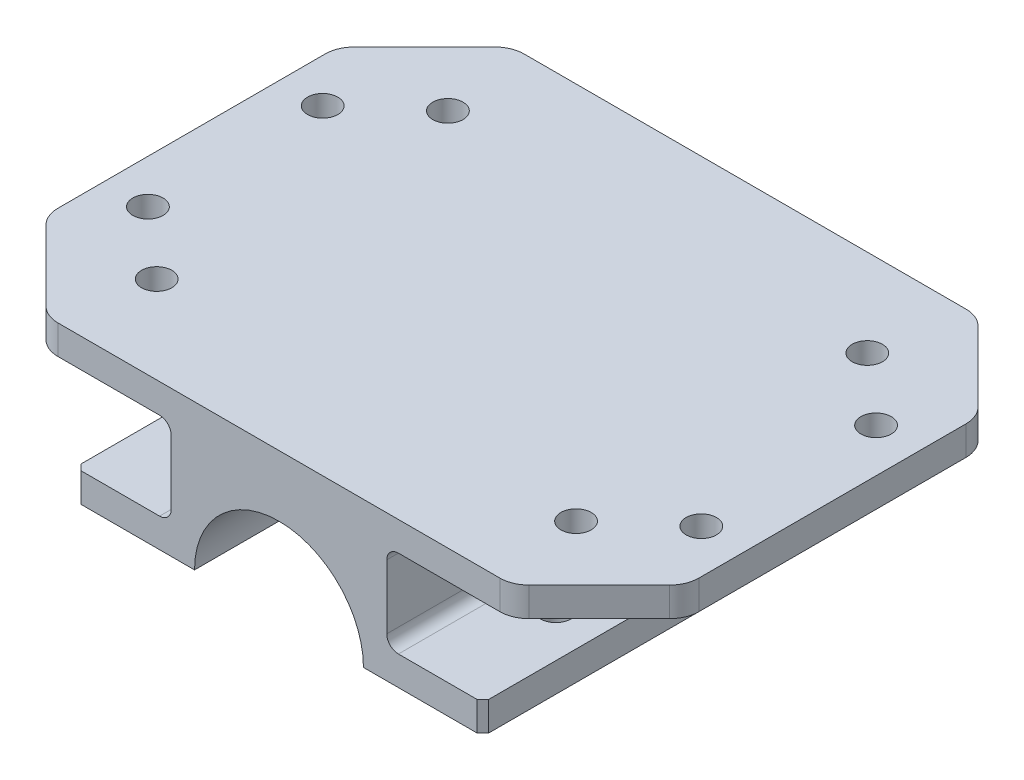
from build123d import *

# Parameters (mm, degrees)
EXTRUDE_2_DEPTH     = 40
SKETCH_3_R          = 2.6
CUT_EXTRUDE_2_DEPTH = 20
CHAMFER_2_SIZE      = 1
SKETCH_4_R          = 2.6
CUT_EXTRUDE_3_DEPTH = 10
SKETCH_5_R          = 2.6
CUT_EXTRUDE_4_DEPTH = 10
CHAMFER_3_SIZE      = 15
FILLET_2_R          = 5
SKETCH1_W           = 4
SKETCH1_H           = 15
CUT_EXTRUDE1_DEPTH  = 81
FILLET1_R           = 2


with BuildPart() as part:
    # 草图2 → 凸台-拉伸2 (new body, symmetric)
    with BuildSketch(Plane.XY):
        with BuildLine():
            Line((25, 0), (14.5, 0))
            ThreePointArc((14.5, 0), (0, 14.5), (-14.5, 0))
            Line((-14.5, 0), (-25, 0))
            Line((-25, 0), (-35, 0))
            Line((-35, 0), (-35, 5))
            Line((-35, 5), (-22.5, 5))
            Line((-22.5, 5), (-22.5, 20))
            Line((-22.5, 20), (-35, 20))
            Line((-35, 20), (-55, 20))
            Line((-55, 20), (-55, 25))
            Line((-55, 25), (-35, 25))
            Line((-35, 25), (35, 25))
            Line((35, 25), (55, 25))
            Line((55, 25), (55, 20))
            Line((55, 20), (35, 20))
            Line((35, 20), (22.5, 20))
            Line((22.5, 20), (22.5, 5))
            Line((22.5, 5), (35, 5))
            Line((35, 5), (35, 0))
            Line((35, 0), (25, 0))
        make_face()
    extrude(amount=EXTRUDE_2_DEPTH, both=True)

    # 草图3 → 切除-拉伸2 (cut)
    with BuildSketch(Plane.XZ.offset(-20)):
        with Locations((-27.5, 20)):
            Circle(SKETCH_3_R)
        with Locations((27.5, 20)):
            Circle(SKETCH_3_R)
        with Locations((27.5, -20)):
            Circle(SKETCH_3_R)
        with Locations((-27.5, -20)):
            Circle(SKETCH_3_R)
    extrude(amount=CUT_EXTRUDE_2_DEPTH, mode=Mode.SUBTRACT)

    # 倒角2
    chamfer_2_edges = [part.edges().sort_by_distance(p)[0] for p in [
        (-35, 2.5, 40),
        (35, 2.5, -40),
        (-35, 2.5, -40),
        (35, 2.5, 40),
    ]]
    chamfer(chamfer_2_edges, length=CHAMFER_2_SIZE)

    # 草图4 → 切除-拉伸3 (cut)
    with BuildSketch(Plane(origin=(0, 25, 0), x_dir=(1, 0, 0), z_dir=(0, 1, 0))):
        with Locations((36, -25)):
            Circle(SKETCH_4_R)
        with Locations((-36, -25)):
            Circle(SKETCH_4_R)
        with Locations((36, 25)):
            Circle(SKETCH_4_R)
        with Locations((-36, 25)):
            Circle(SKETCH_4_R)
    extrude(amount=-CUT_EXTRUDE_3_DEPTH, mode=Mode.SUBTRACT)

    # 草图5 → 切除-拉伸4 (cut)
    with BuildSketch(Plane(origin=(0, 25, 0), x_dir=(1, 0, 0), z_dir=(0, 1, 0))):
        with Locations((-47.5, 15)):
            Circle(SKETCH_5_R)
        with Locations((47.5, 15)):
            Circle(SKETCH_5_R)
        with Locations((47.5, -15)):
            Circle(SKETCH_5_R)
        with Locations((-47.5, -15)):
            Circle(SKETCH_5_R)
    extrude(amount=-CUT_EXTRUDE_4_DEPTH, mode=Mode.SUBTRACT)

    # 倒角3
    chamfer_3_edges = [part.edges().sort_by_distance(p)[0] for p in [
        (-55, 22.5, -40),
        (55, 22.5, -40),
        (55, 22.5, 40),
        (-55, 22.5, 40),
    ]]
    chamfer(chamfer_3_edges, length=CHAMFER_3_SIZE)

    # 圆角2
    fillet_2_edges = [part.edges().sort_by_distance(p)[0] for p in [
        (55, 22.5, 25),
        (55, 22.5, -25),
        (-40, 22.5, -40),
        (40, 22.5, -40),
        (-40, 22.5, 40),
        (40, 22.5, 40),
        (-55, 22.5, 25),
        (-55, 22.5, -25),
    ]]
    fillet(fillet_2_edges, radius=FILLET_2_R)

    # Sketch1 → Cut-Extrude1 (cut, through all)
    with BuildSketch(Plane.XY.offset(40)):
        with Locations((-20.5, 12.5)):
            Rectangle(SKETCH1_W, SKETCH1_H)
        with Locations((20.5, 12.5)):
            Rectangle(SKETCH1_W, SKETCH1_H)
    extrude(amount=-CUT_EXTRUDE1_DEPTH, mode=Mode.SUBTRACT)

    # Fillet1
    fillet1_edges = [part.edges().sort_by_distance(p)[0] for p in [
        (-18.5, 20, 0),
        (-18.5, 5, 0),
        (18.5, 5, 0),
        (18.5, 20, 0),
    ]]
    fillet(fillet1_edges, radius=FILLET1_R)


solid = part.part
